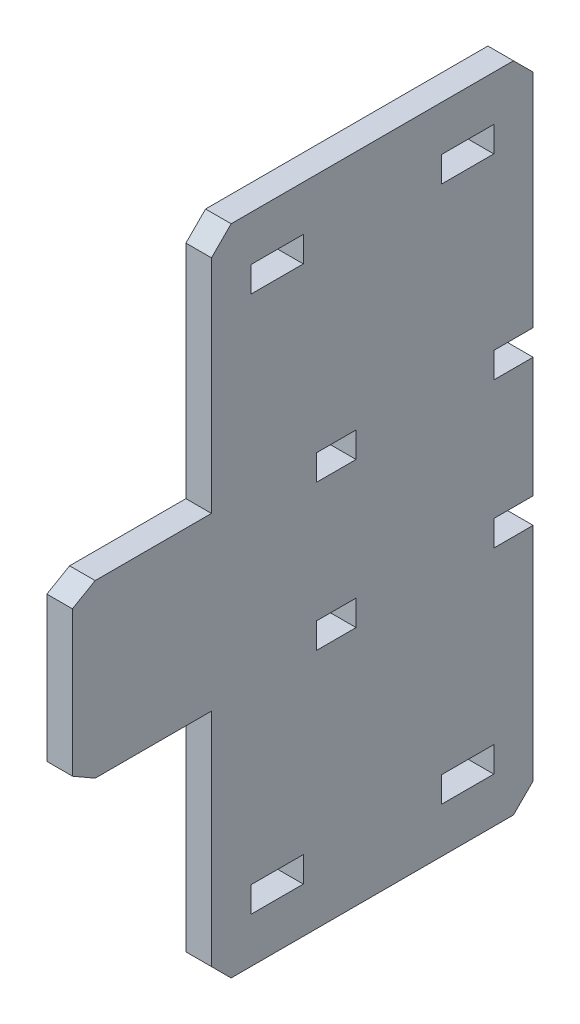
from build123d import *

# Parameters (mm, degrees)
SKETCH1_W           = 10.16
SKETCH1_H           = 4.953
SKETCH1_W_2         = 7.62
BOSS_EXTRUDE1_DEPTH = 2.4765
CHAMFER2_SIZE       = 3.81


with BuildPart() as part:
    # Sketch1 → Boss-Extrude1 (new, symmetric)
    with BuildSketch(Plane(origin=(0, 0, 0), x_dir=(0, 0, -1), z_dir=(1, 0, 0))):
        Polygon((45.72, -63.246), (45.72, -16.5735), (38.1, -16.5735), (38.1, -11.6205), (45.72, -11.6205), (45.72, 11.6205), (38.1, 11.6205), (38.1, 16.5735), (45.72, 16.5735), (45.72, 63.246), (-16.571856626, 63.246), (-16.571856626, 16.5735), (-39.096447575, 16.5735), (-43.495856626, 14.0335), (-43.495856626, -14.0335), (-39.096447575, -16.5735), (-16.571856626, -16.5735), (-16.571856626, -63.246), align=None)
        with Locations((33.02, -52.0065)):
            Rectangle(SKETCH1_W, SKETCH1_H, mode=Mode.SUBTRACT)
        with Locations((33.02, 52.0065)):
            Rectangle(SKETCH1_W, SKETCH1_H, mode=Mode.SUBTRACT)
        with Locations((-3.871856626, 52.0065)):
            Rectangle(SKETCH1_W, SKETCH1_H, mode=Mode.SUBTRACT)
        with Locations((-3.871856626, -52.0065)):
            Rectangle(SKETCH1_W, SKETCH1_H, mode=Mode.SUBTRACT)
        with Locations((7.62, 14.097)):
            Rectangle(SKETCH1_W_2, SKETCH1_H, mode=Mode.SUBTRACT)
        with Locations((7.62, -14.097)):
            Rectangle(SKETCH1_W_2, SKETCH1_H, mode=Mode.SUBTRACT)
    extrude(amount=BOSS_EXTRUDE1_DEPTH, both=True)

    # Chamfer2
    chamfer2_edges = [part.edges().sort_by_distance(p)[0] for p in [
        (0, -63.246, -45.72),
        (0, -63.246, 16.571856626),
        (0, 63.246, -45.72),
        (0, 63.246, 16.571856626),
    ]]
    chamfer(chamfer2_edges, length=CHAMFER2_SIZE)


solid = part.part
